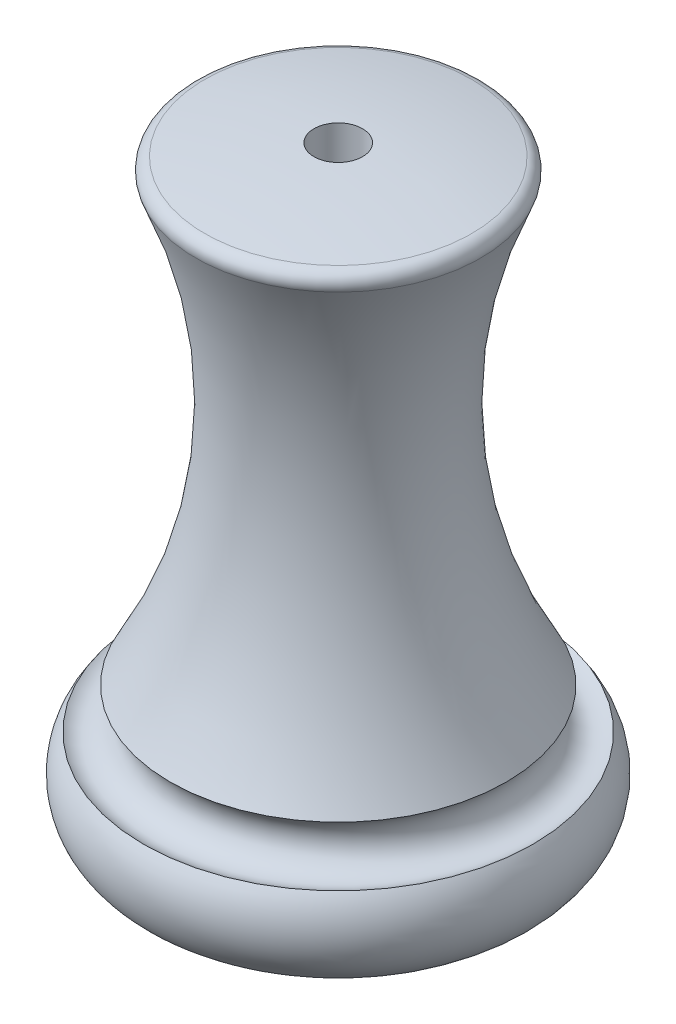
from build123d import *

# Parameters (mm, degrees)
SKETCH2_R          = 2
SKETCH3_R          = 2
CUT_EXTRUDE1_DEPTH = 51


with BuildPart() as part:
    # Sketch1 → Revolve1 (revolve)
    with BuildSketch(Plane(origin=(0, 0, 0), x_dir=(0, 0, -1), z_dir=(1, 0, 0))):
        with BuildLine():
            Line((0, 0), (0, 50))
            ThreePointArc((0, 50), (5.523447707, 49.745221779), (10.999986942, 48.983050847))
            ThreePointArc((10.999986942, 48.983050847), (11.700701157, 48.467397387), (11.732280918, 47.597971357))
            ThreePointArc((11.732280918, 47.597971357), (8.591312849, 27.196972532), (16.039707174, 7.946313959))
            ThreePointArc((16.039707174, 7.946313959), (16.457104991, 2.734119354), (12, 0))
            Line((12, 0), (0, 0))
        make_face()
    revolve(axis=Axis((0, 0, 0), (0, 1, 0)))

    # Sketch2 → Cut-Revolve1 (revolve, cut)
    with BuildSketch(Plane(origin=(0, 0, 0), x_dir=(0, 0, -1), z_dir=(1, 0, 0))):
        with Locations((14.901947009, 9.591154926)):
            Circle(SKETCH2_R)
    revolve(axis=Axis((0, 0, 0), (0, 1, 0)), mode=Mode.SUBTRACT)

    # Sketch3 → Cut-Extrude1 (cut, through all)
    with BuildSketch(Plane.XZ):
        Circle(SKETCH3_R)
    extrude(amount=-CUT_EXTRUDE1_DEPTH, mode=Mode.SUBTRACT)


solid = part.part
